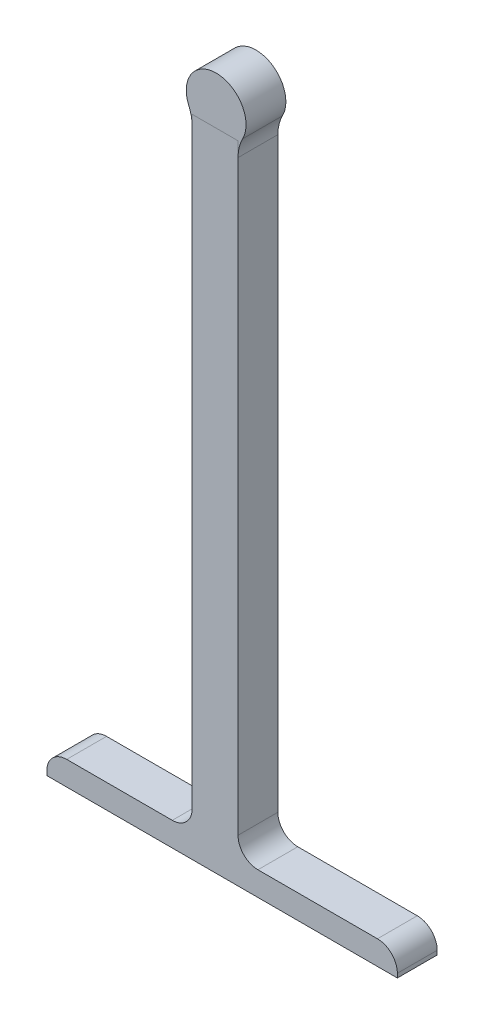
from build123d import *

# Parameters (mm, degrees)
SKETCH1_R                = 7.5
BOSS_EXTRUDE2_DEPTH      = 10
SKETCH3_W                = 11.5
SKETCH3_H                = 162
BOSS_EXTRUDE3_DEPTH      = 0.001
BOSS_EXTRUDE3_DEPTH_BACK = 10
SKETCH4_W                = 10.001
SKETCH4_H                = 6.029708674
BOSS_EXTRUDE4_DEPTH      = 40
BOSS_EXTRUDE4_DEPTH_BACK = 48
FILLET1_R                = 10
FILLET2_R                = 10
FILLET3_R                = 5
FILLET4_R                = 5
FILLET5_R                = 5
FILLET6_R                = 5


with BuildPart() as part:
    # Sketch1 → Boss-Extrude2 (new body)
    with BuildSketch(Plane.XY):
        Circle(SKETCH1_R)
    extrude(amount=BOSS_EXTRUDE2_DEPTH)

    # Sketch3 → Boss-Extrude3 (add, two sides)
    with BuildSketch(Plane.XY.offset(10)) as boss_extrude3_sk:
        with Locations((-0.261803669, -85.484218622)):
            Rectangle(SKETCH3_W, SKETCH3_H)
    extrude(amount=BOSS_EXTRUDE3_DEPTH)
    extrude(boss_extrude3_sk.sketch, amount=-BOSS_EXTRUDE3_DEPTH_BACK)

    # Sketch4 → Boss-Extrude4 (add, two sides)
    with BuildSketch(Plane(origin=(5.488196331, 0, 0), x_dir=(0, 0, -1), z_dir=(1, 0, 0))) as boss_extrude4_sk:
        with Locations((-5.0005, -163.469364285)):
            Rectangle(SKETCH4_W, SKETCH4_H)
    extrude(amount=BOSS_EXTRUDE4_DEPTH)
    extrude(boss_extrude4_sk.sketch, amount=-BOSS_EXTRUDE4_DEPTH_BACK)

    # Fillet1
    fillet1_edges = [part.edges().sort_by_distance(p)[0] for p in [
        (5.488196331, -5.111721924, 5),
    ]]
    fillet(fillet1_edges, radius=FILLET1_R)

    # Fillet2
    fillet2_edges = [part.edges().sort_by_distance(p)[0] for p in [
        (-6.011803669, -4.484218622, 5),
    ]]
    fillet(fillet2_edges, radius=FILLET2_R)

    # Fillet3
    fillet3_edges = [part.edges().sort_by_distance(p)[0] for p in [
        (5.488196331, -160.454509948, 5.0005),
    ]]
    fillet(fillet3_edges, radius=FILLET3_R)

    # Fillet4
    fillet4_edges = [part.edges().sort_by_distance(p)[0] for p in [
        (-6.011803669, -160.454509948, 5.0005),
    ]]
    fillet(fillet4_edges, radius=FILLET4_R)

    # Fillet5
    fillet5_edges = [part.edges().sort_by_distance(p)[0] for p in [
        (-42.511803669, -160.454509948, 5.0005),
    ]]
    fillet(fillet5_edges, radius=FILLET5_R)

    # Fillet6
    fillet6_edges = [part.edges().sort_by_distance(p)[0] for p in [
        (45.488196331, -160.454509948, 5.0005),
    ]]
    fillet(fillet6_edges, radius=FILLET6_R)


solid = part.part
